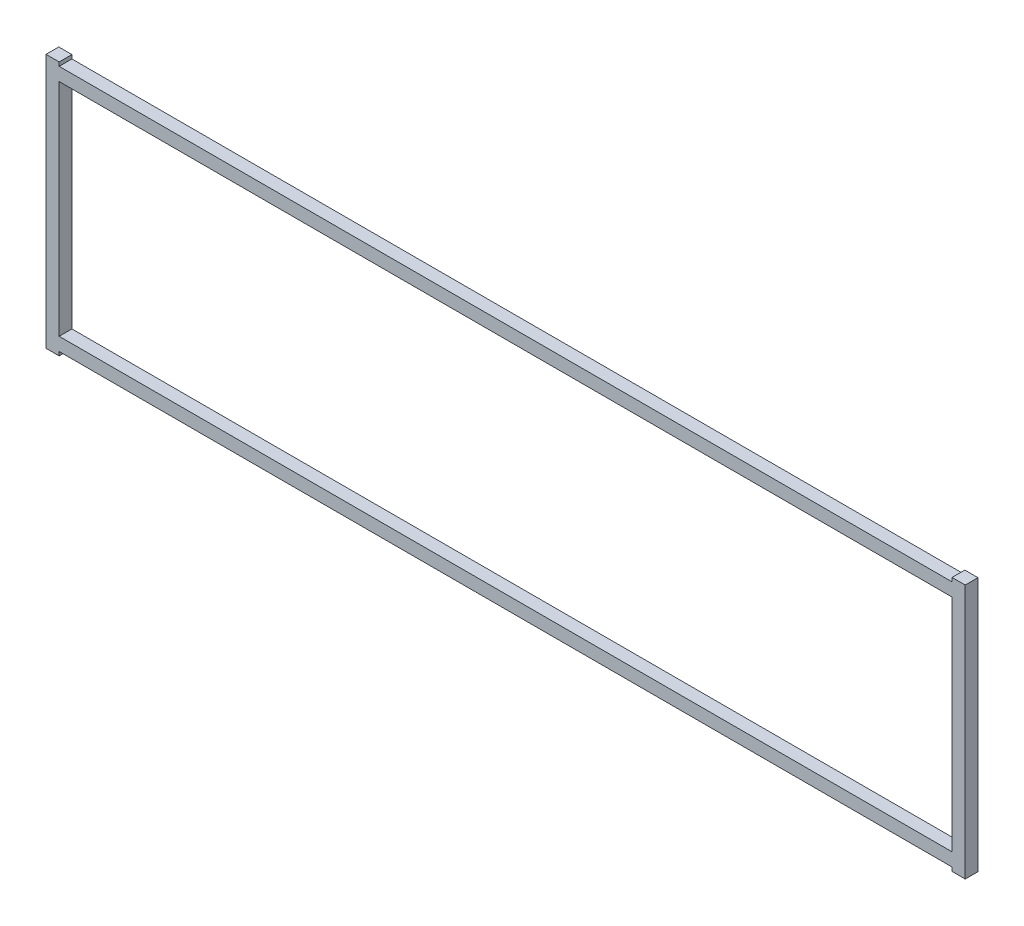
from build123d import *

# Parameters (mm, degrees)
SKETCH1_W           = 444.2968
SKETCH1_H           = 109.78515
BOSS_EXTRUDE1_DEPTH = 6.35


with BuildPart() as part:
    # Sketch1 → Boss-Extrude1 (new body)
    with BuildSketch(Plane.XY):
        Polygon((222.1484, -63.35395), (228.7016, -63.35395), (228.7016, 63.35395), (222.1484, 63.35395), (222.1484, 61.445775), (-222.1484, 61.445775), (-222.1484, 63.35395), (-228.7016, 63.35395), (-228.7016, -63.35395), (-222.1484, -63.35395), (-222.1484, -61.445775), (222.1484, -61.445775), align=None)
        Rectangle(SKETCH1_W, SKETCH1_H, mode=Mode.SUBTRACT)
    extrude(amount=BOSS_EXTRUDE1_DEPTH)


solid = part.part
